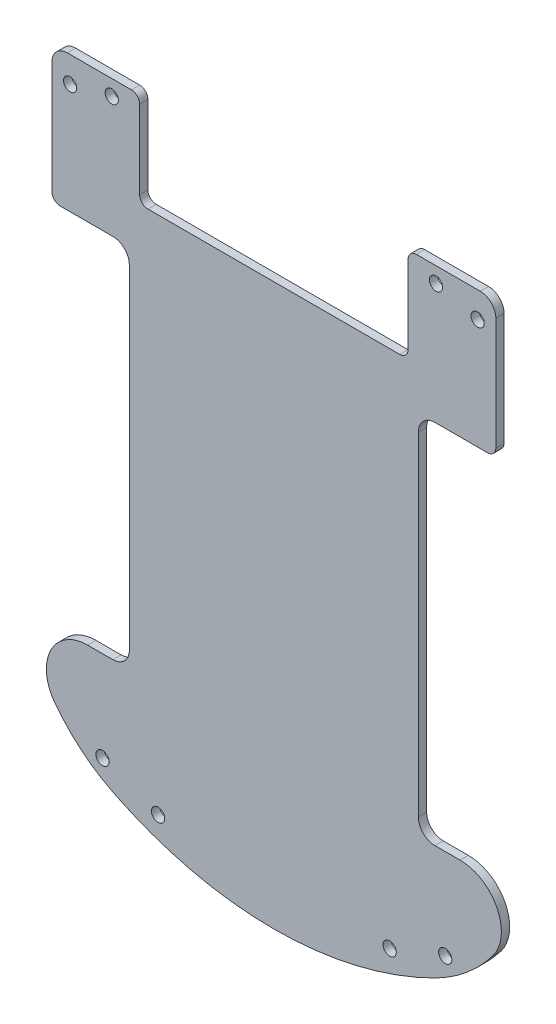
from build123d import *

# Parameters (mm, degrees)
SKETCH1_R                = 1.6
BOSS_EXTRUDE1_DEPTH      = 2
M3_CLEARANCE_HOLE1_D     = 3.2
M3_CLEARANCE_HOLE1_DEPTH = 2
M3_CLEARANCE_HOLE1_TIP   = 0.96137699


with BuildPart() as part:
    # Sketch1 → Boss-Extrude1 (new body)
    with BuildSketch(Plane(origin=(0, 0, 0), x_dir=(-1, 0, 0), z_dir=(0, 0, -1))):
        with BuildLine():
            Line((49.999999993, 71.749999992), (34.499999968, 71.749999992))
            ThreePointArc((34.499999968, 71.749999992), (33.085786407, 71.164213555), (32.49999997, 69.749999994))
            Line((32.49999997, 69.749999994), (32.49999997, 50.749999994))
            ThreePointArc((32.49999997, 50.749999994), (31.914213535, 49.335786439), (30.49999998, 48.750000004))
            Line((30.49999998, 48.750000004), (-30.50000002, 48.750000004))
            ThreePointArc((-30.50000002, 48.750000004), (-31.914213575, 49.335786439), (-32.50000001, 50.749999994))
            Line((-32.50000001, 50.749999994), (-32.50000001, 69.749999994))
            ThreePointArc((-32.50000001, 69.749999994), (-33.085786447, 71.164213555), (-34.500000007, 71.749999992))
            Line((-34.500000007, 71.749999992), (-50.000000007, 71.749999992))
            ThreePointArc((-50.000000007, 71.749999992), (-52.651650433, 70.651650422), (-53.750000002, 67.999999996))
            Line((-53.750000002, 67.999999996), (-53.750000002, 40.749999996))
            ThreePointArc((-53.750000002, 40.749999996), (-53.164213571, 39.335786449), (-51.750000024, 38.750000018))
            Line((-51.750000024, 38.750000018), (-39.000000024, 38.750000018))
            ThreePointArc((-39.000000024, 38.750000018), (-36.171572886, 37.578427137), (-35.000000005, 34.75))
            Line((-35.000000005, 34.75), (-35.000000005, -46))
            ThreePointArc((-35.000000005, -46), (-36.171572879, -48.828427121), (-38.999999999, -49.999999994))
            Line((-38.999999999, -49.999999994), (-45.09502308, -49.999999994))
            ThreePointArc((-45.09502308, -49.999999994), (-54.039294999, -55.527864046), (-53.095023084, -66.000000011))
            ThreePointArc((-53.095023084, -66.000000011), (-46.752677079, -72.686883058), (-39.048234252, -77.744680848))
            ThreePointArc((-39.048234252, -77.744680848), (1.5e-08, -86.999999997), (39.048234283, -77.744680848))
            ThreePointArc((39.048234283, -77.744680848), (46.752677109, -72.686883058), (53.095023115, -66.000000011))
            ThreePointArc((53.095023115, -66.000000011), (54.039295029, -55.527864046), (45.095023111, -49.999999994))
            Line((45.095023111, -49.999999994), (39.000000001, -49.999999994))
            ThreePointArc((39.000000001, -49.999999994), (36.17157288, -48.828427121), (35.000000007, -46))
            Line((35.000000007, -46), (35.000000007, 34.75))
            ThreePointArc((35.000000007, 34.75), (36.171572888, 37.578427137), (39.000000025, 38.750000018))
            Line((39.000000025, 38.750000018), (51.750000009, 38.750000018))
            ThreePointArc((51.750000009, 38.750000018), (53.164213556, 39.335786449), (53.749999988, 40.749999996))
            Line((53.749999988, 40.749999996), (53.749999988, 67.999999996))
            ThreePointArc((53.749999988, 67.999999996), (52.651650419, 70.651650422), (49.999999993, 71.749999992))
        make_face()
        with Locations((49.348831914, 65.488111827)):
            Circle(SKETCH1_R, mode=Mode.SUBTRACT)
        with Locations((-49.348831883, 65.488111827)):
            Circle(SKETCH1_R, mode=Mode.SUBTRACT)
        with Locations((28.045651768, -77.054794901)):
            Circle(SKETCH1_R, mode=Mode.SUBTRACT)
        with Locations((-28.045651737, -77.054794901)):
            Circle(SKETCH1_R, mode=Mode.SUBTRACT)
    extrude(amount=-BOSS_EXTRUDE1_DEPTH)

    # M3 Clearance Hole1
    with Locations(Plane(origin=(-39.259818305, 68, 2), x_dir=(1, 0, 0), z_dir=(0, 0, 1))):
        with Locations((0, 0), (78.51963661, 0), (80.759818305, -139.880108514), (-2.240181695, -139.880108514)):
            Hole(M3_CLEARANCE_HOLE1_D / 2, depth=M3_CLEARANCE_HOLE1_DEPTH)
            with Locations((0, 0, -(M3_CLEARANCE_HOLE1_DEPTH + M3_CLEARANCE_HOLE1_TIP / 2))):  # 118° drill point
                Cone(0, M3_CLEARANCE_HOLE1_D / 2, M3_CLEARANCE_HOLE1_TIP, mode=Mode.SUBTRACT)


solid = part.part
